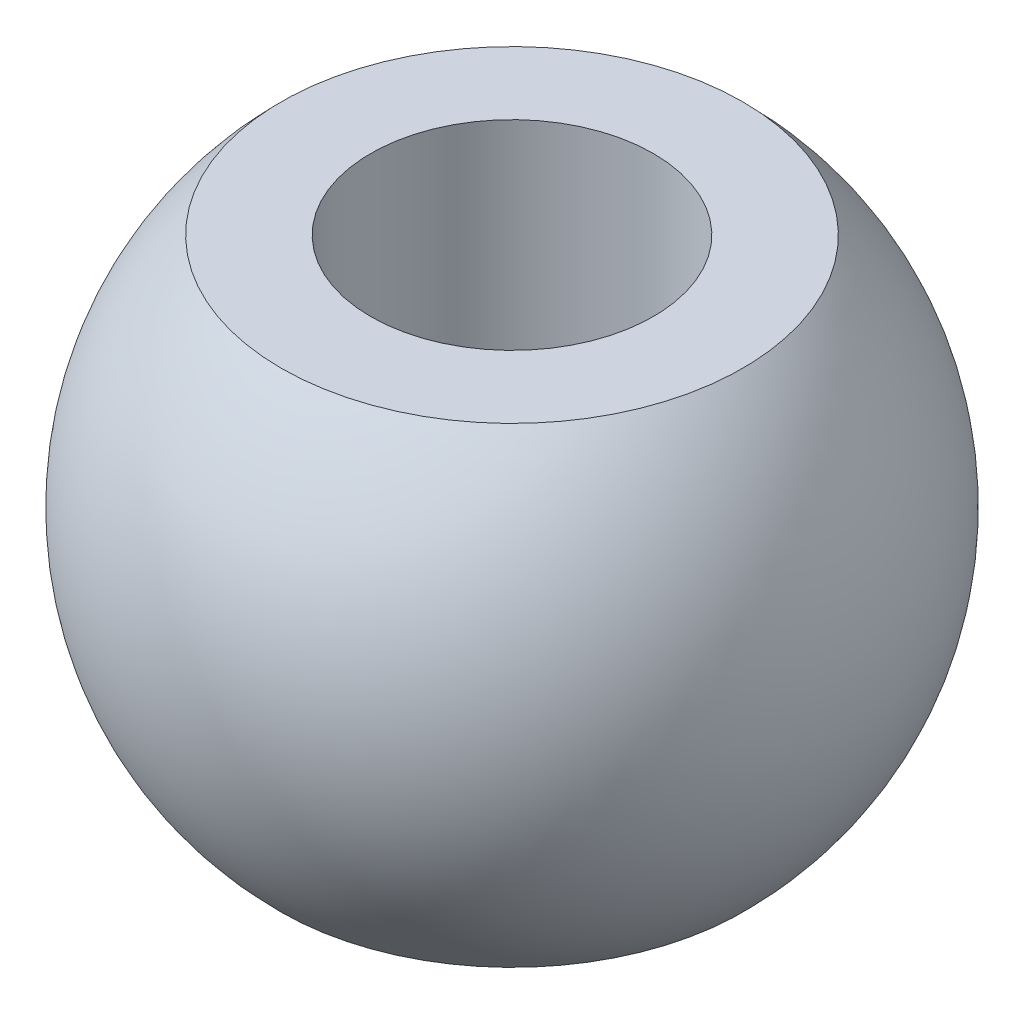
from build123d import *


with BuildPart() as part:
    # Sketch1 → Revolve1 (revolve)
    with BuildSketch(Plane.XY):
        with BuildLine():
            Line((-1.5, 2.5), (-1.5, -2.5))
            Line((-1.5, -2.5), (-2.449489743, -2.5))
            ThreePointArc((-2.449489743, -2.5), (-3.5, 0), (-2.449489743, 2.5))
            Line((-2.449489743, 2.5), (-1.5, 2.5))
        make_face()
    revolve(axis=Axis((0, 3.246268657, 0), (0, -1, 0)))


solid = part.part
